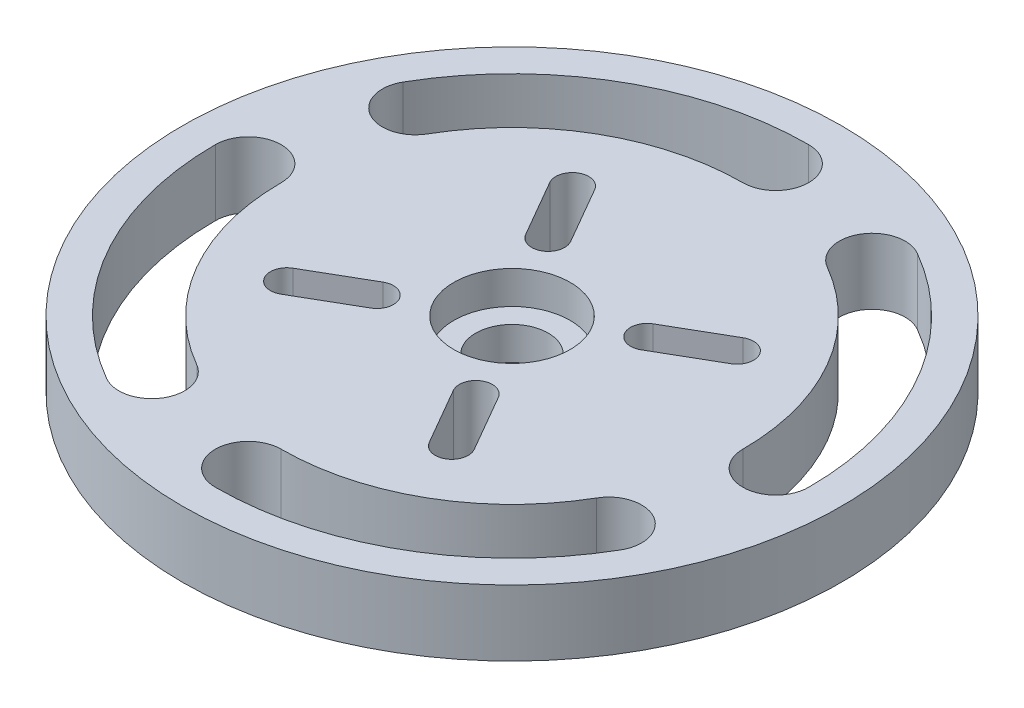
from build123d import *

# Parameters (mm, degrees)
SKETCH_1_R          = 15
EXTRUDE_2_DEPTH     = 3
SKETCH_2_R          = 1.65
CUT_EXTRUDE_2_DEPTH = 17
SKETCH_2_4_R        = 2.65
SKETCH_2_4_R_2      = 1.65
CUT_EXTRUDE_3_DEPTH = 1.5


with BuildPart() as part:
    # 草图1 → 凸台-拉伸2 (new body)
    with BuildSketch(Plane(origin=(0, 0, 0), x_dir=(1, 0, 0), z_dir=(0, 1, 0))):
        Circle(SKETCH_1_R)
    extrude(amount=EXTRUDE_2_DEPTH)

    # 草图2 → 切除-拉伸2 (cut)
    with BuildSketch(Plane(origin=(0, 3, 0), x_dir=(1, 0, 0), z_dir=(0, 1, 0))):
        with BuildLine():
            Line((-4.400758471, 6.119299378), (-2.900232319, 3.521527012))
            ThreePointArc((-2.900232319, 3.521527012), (-1.87565769, 3.247215458), (-1.601346136, 4.271790088))
            Line((-1.601346136, 4.271790088), (-3.101872288, 6.869562454))
            ThreePointArc((-3.101872288, 6.869562454), (-4.126446917, 7.143874008), (-4.400758471, 6.119299378))
        make_face()
        with BuildLine():
            Line((6.119299378, 4.400758471), (3.521527012, 2.900232319))
            ThreePointArc((3.521527012, 2.900232319), (3.247215458, 1.87565769), (4.271790088, 1.601346136))
            Line((4.271790088, 1.601346136), (6.869562454, 3.101872288))
            ThreePointArc((6.869562454, 3.101872288), (7.143874008, 4.126446917), (6.119299378, 4.400758471))
        make_face()
        with BuildLine():
            Line((4.400758471, -6.119299378), (2.900232319, -3.521527012))
            ThreePointArc((2.900232319, -3.521527012), (1.87565769, -3.247215458), (1.601346136, -4.271790088))
            Line((1.601346136, -4.271790088), (3.101872288, -6.869562454))
            ThreePointArc((3.101872288, -6.869562454), (4.126446917, -7.143874008), (4.400758471, -6.119299378))
        make_face()
        with BuildLine():
            Line((-6.119299378, -4.400758471), (-3.521527012, -2.900232319))
            ThreePointArc((-3.521527012, -2.900232319), (-3.247215458, -1.87565769), (-4.271790088, -1.601346136))
            Line((-4.271790088, -1.601346136), (-6.869562454, -3.101872288))
            ThreePointArc((-6.869562454, -3.101872288), (-7.143874008, -4.126446917), (-6.119299378, -4.400758471))
        make_face()
        Circle(SKETCH_2_R)
        with BuildLine():
            ThreePointArc((0, 10.504705492), (1.5, 12.004705492), (0, 13.504705492))
            ThreePointArc((0, 13.504705492), (-6.754721254, 11.694050248), (-11.698152145, 6.747614899))
            ThreePointArc((-11.698152145, 6.747614899), (-11.14828411, 4.698799352), (-9.099468564, 5.248667387))
            ThreePointArc((-9.099468564, 5.248667387), (-5.254195103, 9.096277882), (0, 10.504705492))
        make_face()
        with BuildLine():
            ThreePointArc((10.504705492, 0), (12.004705492, -1.5), (13.504705492, 0))
            ThreePointArc((13.504705492, 0), (11.694050248, 6.754721254), (6.747614899, 11.698152145))
            ThreePointArc((6.747614899, 11.698152145), (4.698799352, 11.14828411), (5.248667387, 9.099468564))
            ThreePointArc((5.248667387, 9.099468564), (9.096277882, 5.254195103), (10.504705492, 0))
        make_face()
        with BuildLine():
            ThreePointArc((0, -10.504705492), (-1.5, -12.004705492), (0, -13.504705492))
            ThreePointArc((0, -13.504705492), (6.754721254, -11.694050248), (11.698152145, -6.747614899))
            ThreePointArc((11.698152145, -6.747614899), (11.14828411, -4.698799352), (9.099468564, -5.248667387))
            ThreePointArc((9.099468564, -5.248667387), (5.254195103, -9.096277882), (0, -10.504705492))
        make_face()
        with BuildLine():
            ThreePointArc((-10.504705492, 0), (-12.004705492, 1.5), (-13.504705492, 0))
            ThreePointArc((-13.504705492, 0), (-11.694050248, -6.754721254), (-6.747614899, -11.698152145))
            ThreePointArc((-6.747614899, -11.698152145), (-4.698799352, -11.14828411), (-5.248667387, -9.099468564))
            ThreePointArc((-5.248667387, -9.099468564), (-9.096277882, -5.254195103), (-10.504705492, 0))
        make_face()
    extrude(amount=-CUT_EXTRUDE_2_DEPTH, mode=Mode.SUBTRACT)

    # 草图2<4> → 切除-拉伸3 (cut)
    with BuildSketch(Plane(origin=(0, 3, 0), x_dir=(1, 0, 0), z_dir=(0, 1, 0))):
        Circle(SKETCH_2_4_R)
        Circle(SKETCH_2_4_R_2, mode=Mode.SUBTRACT)
    extrude(amount=-CUT_EXTRUDE_3_DEPTH, mode=Mode.SUBTRACT)


solid = part.part
